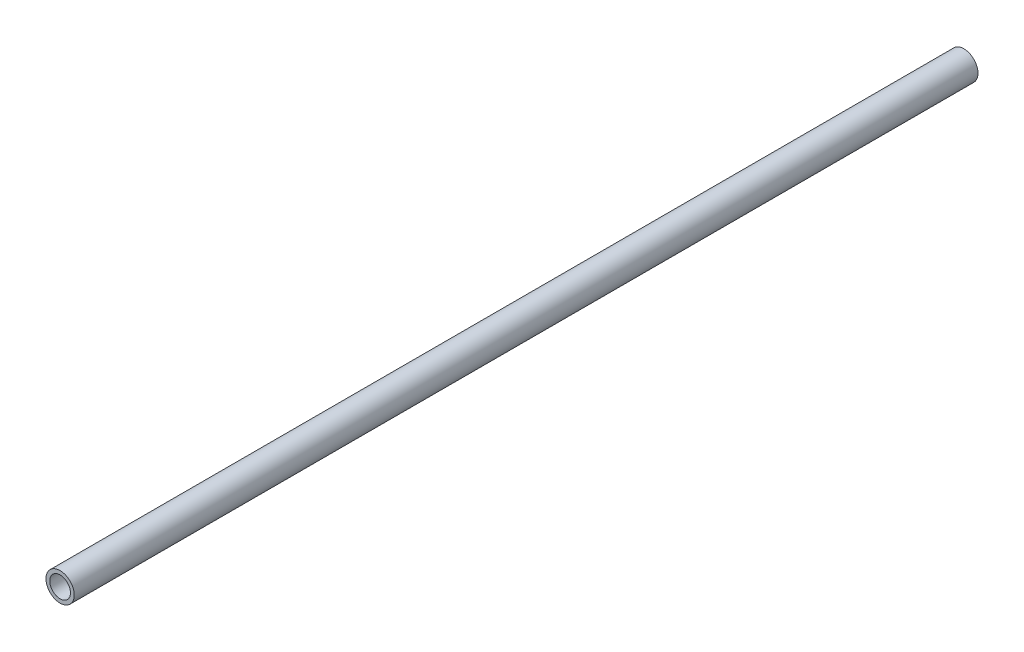
from build123d import *

# Parameters (mm, degrees)
SKETCH1_R           = 9.525
SKETCH1_R_2         = 6.985
BOSS_EXTRUDE1_DEPTH = 609.6


with BuildPart() as part:
    # Sketch1 → Boss-Extrude1 (new body)
    with BuildSketch(Plane.XY):
        Circle(SKETCH1_R)
        Circle(SKETCH1_R_2, mode=Mode.SUBTRACT)
    extrude(amount=BOSS_EXTRUDE1_DEPTH)


solid = part.part
